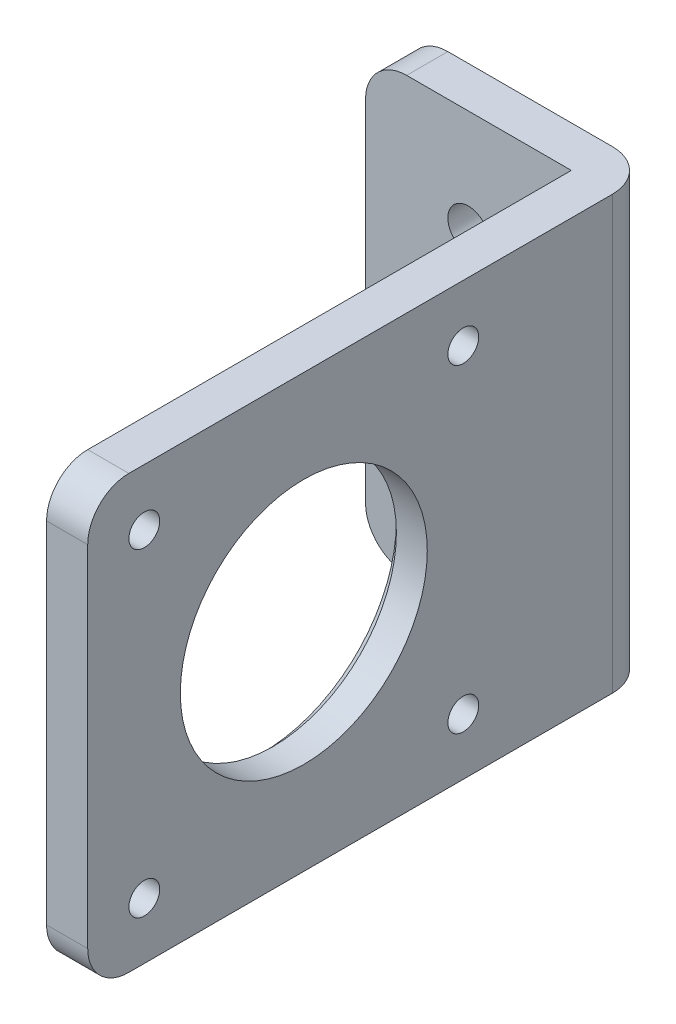
from build123d import *

# Parameters (mm, degrees)
BOSS_EXTRUDE1_DEPTH = 42
SKETCH2_R           = 12
SKETCH2_R_2         = 1.5
CUT_EXTRUDE1_DEPTH  = 5
SKETCH3_R           = 2
CUT_EXTRUDE2_DEPTH  = 5
CHAMFER2_SIZE       = 1
FILLET1_R           = 4


with BuildPart() as part:
    # Sketch1 → Boss-Extrude1 (new body)
    with BuildSketch(Plane(origin=(0, 0, 0), x_dir=(1, 0, 0), z_dir=(0, 1, 0))):
        Polygon((0, 0), (0, 51), (-20, 51), (-20, 55), (4, 55), (4, 0), align=None)
    extrude(amount=BOSS_EXTRUDE1_DEPTH)

    # Sketch2 → Cut-Extrude1 (cut, through all)
    with BuildSketch(Plane.ZY):
        with Locations((-21, 21)):
            Circle(SKETCH2_R)
        with Locations((-36.5, 36.5)):
            Circle(SKETCH2_R_2)
        with Locations((-5.5, 36.5)):
            Circle(SKETCH2_R_2)
        with Locations((-5.5, 5.5)):
            Circle(SKETCH2_R_2)
        with Locations((-36.5, 5.5)):
            Circle(SKETCH2_R_2)
    extrude(amount=-CUT_EXTRUDE1_DEPTH, mode=Mode.SUBTRACT)

    # Sketch3 → Cut-Extrude2 (cut, through all)
    with BuildSketch(Plane.XY.offset(-51)):
        with Locations((-10, 32)):
            Circle(SKETCH3_R)
        with Locations((-10, 10)):
            Circle(SKETCH3_R)
    extrude(amount=-CUT_EXTRUDE2_DEPTH, mode=Mode.SUBTRACT)

    # Chamfer2
    chamfer2_edges = [part.edges().sort_by_distance(p)[0] for p in [
        (0, 21, -33),
    ]]
    chamfer(chamfer2_edges, length=CHAMFER2_SIZE)

    # Fillet1
    fillet1_edges = [part.edges().sort_by_distance(p)[0] for p in [
        (4, 21, -55),
        (-20, 42, -53),
        (2, 42, 0),
        (-20, 0, -53),
        (2, 0, 0),
    ]]
    fillet(fillet1_edges, radius=FILLET1_R)


solid = part.part
